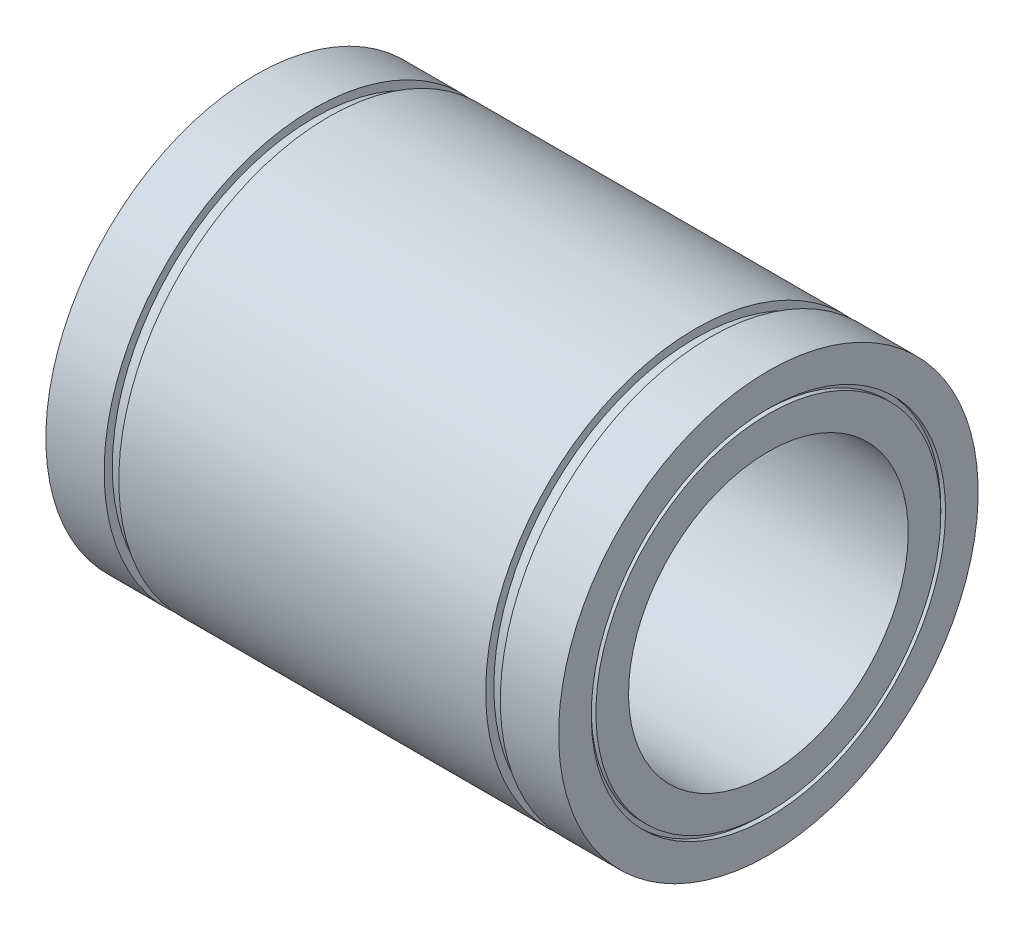
from build123d import *


with BuildPart() as part:
    # Esboço1 → Revolução1 (revolve)
    with BuildSketch(Plane.XY):
        Polygon((-55, 45), (-42.5, 45), (-42.5, 43.25), (-39.35, 43.25), (-39.35, 45), (39.35, 45), (39.35, 43.25), (42.5, 43.25), (42.5, 45), (55, 45), (55, 38), (54, 38), (54, 37), (55, 37), (55, 30), (-55, 30), (-55, 37), (-54, 37), (-54, 38), (-55, 38), align=None)
    revolve(axis=Axis((0, 0, 0), (-1, 0, 0)))


solid = part.part
